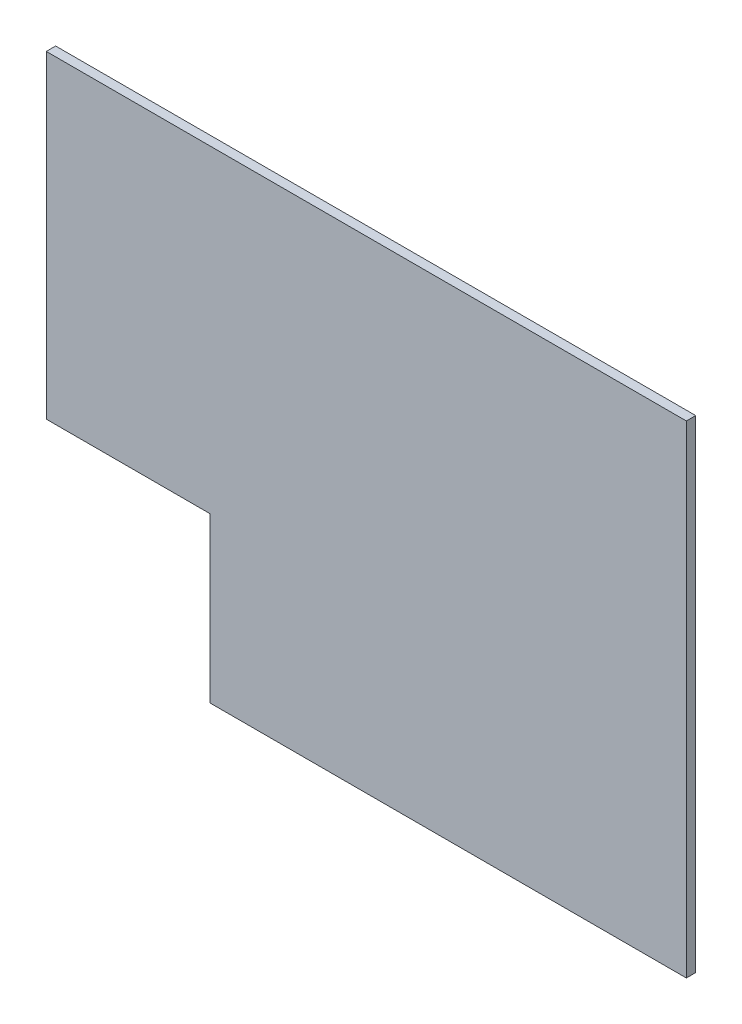
from build123d import *

# Parameters (mm, degrees)
BOSS_EXTRU_1_DEPTH = 3


with BuildPart() as part:
    # Esquisse1 → Boss.-Extru.1 (new body)
    with BuildSketch(Plane.XY):
        Polygon((46.961764933, -31.997174942), (46.961764933, 20.502825058), (-5.538235067, 20.502825058), (-5.538235067, 122.502825058), (199.461764933, 122.502825058), (199.461764933, -31.997174942), align=None)
    extrude(amount=BOSS_EXTRU_1_DEPTH)


solid = part.part
